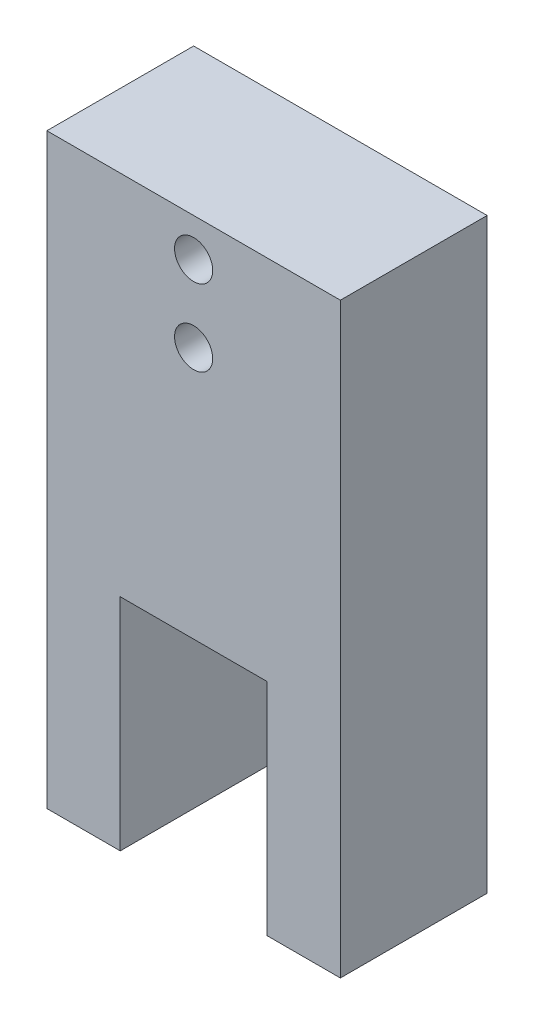
from build123d import *

# Parameters (mm, degrees)
SKETCH2_R           = 3.302
BOSS_EXTRUDE1_DEPTH = 25.4


with BuildPart() as part:
    # Sketch2 → Boss-Extrude1 (new body)
    with BuildSketch(Plane.XY):
        Polygon((0, 101.6), (0, 0), (12.7, 0), (12.7, 38.1), (38.1, 38.1), (38.1, 0), (50.8, 0), (50.8, 101.6), align=None)
        with Locations((25.4, 81.788)):
            Circle(SKETCH2_R, mode=Mode.SUBTRACT)
        with Locations((25.4, 94.996)):
            Circle(SKETCH2_R, mode=Mode.SUBTRACT)
    extrude(amount=BOSS_EXTRUDE1_DEPTH)


solid = part.part
